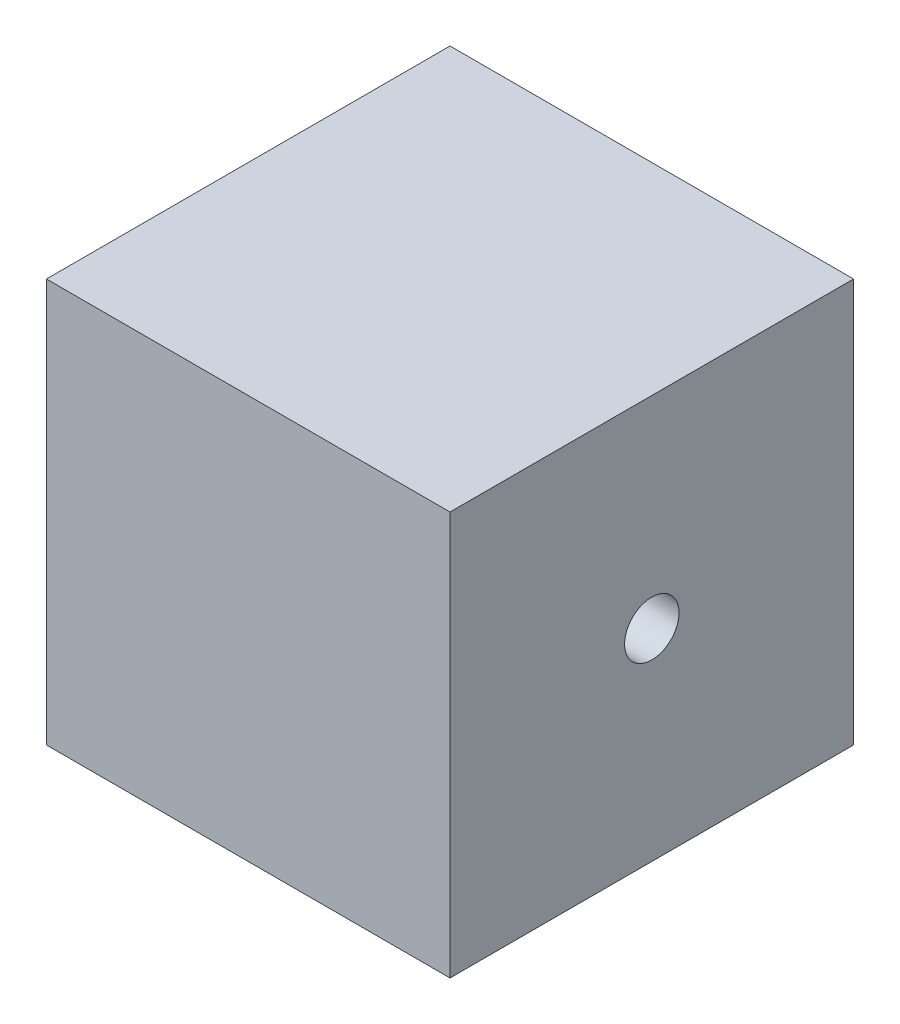
from build123d import *

# Parameters (mm, degrees)
SKETCH1_W           = 20
SKETCH1_H           = 20
BOSS_EXTRUDE1_DEPTH = 20
SKETCH2_R           = 1.349385492
CUT_EXTRUDE1_DEPTH  = 20


with BuildPart() as part:
    # Sketch1 → Boss-Extrude1 (new body)
    with BuildSketch(Plane(origin=(0, 0, 0), x_dir=(1, 0, 0), z_dir=(0, 1, 0))):
        Rectangle(SKETCH1_W, SKETCH1_H)
    extrude(amount=BOSS_EXTRUDE1_DEPTH)

    # Sketch2 → Cut-Extrude1 (cut)
    with BuildSketch(Plane(origin=(10, 0, 0), x_dir=(0, 0, -1), z_dir=(1, 0, 0))):
        with Locations((0, 10)):
            Circle(SKETCH2_R)
    extrude(amount=-CUT_EXTRUDE1_DEPTH, mode=Mode.SUBTRACT)


solid = part.part
